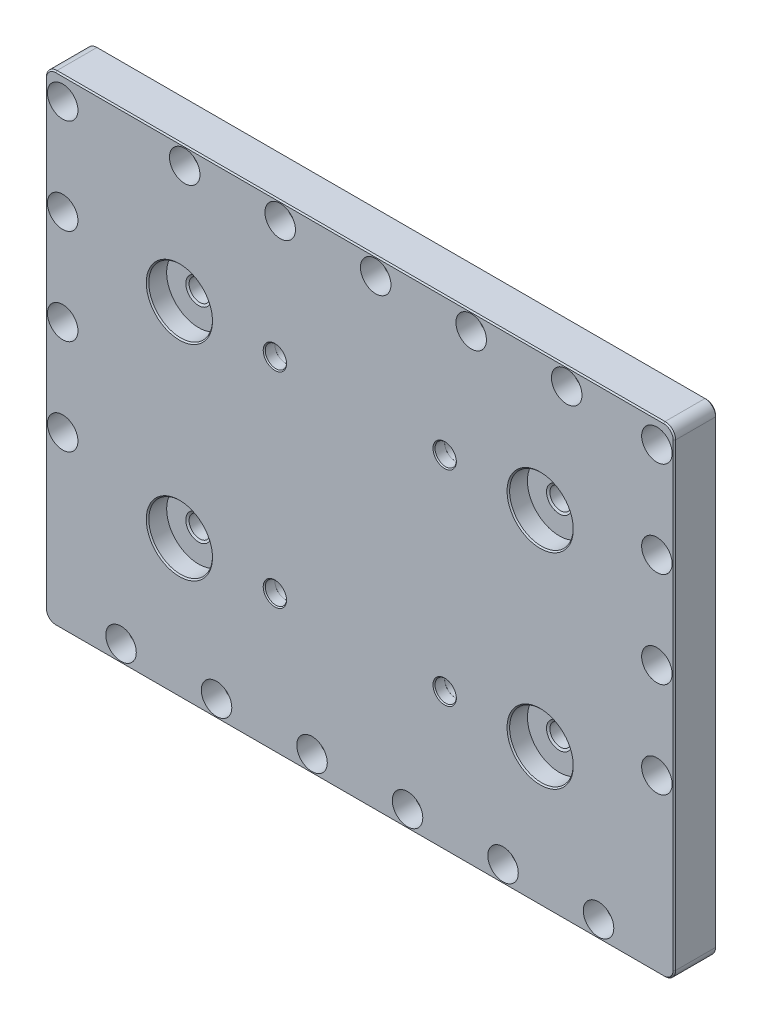
from build123d import *

# Parameters (mm, degrees)
SKETCH1_W                                     = 376.555
SKETCH1_H                                     = 287.655
EXTRUDE1_DEPTH                                = 25.4
CBORE_FOR_3_8_SOCKET_HEAD_CAP_SCREW3_AT_COUNT = 2
CBORE_FOR_3_8_SOCKET_HEAD_CAP_SCREW3_AT_PITCH = 57.15
CBORE_FOR_3_8_SOCKET_HEAD_CAP_SCREW3_2_COUNT  = 2
CBORE_FOR_3_8_SOCKET_HEAD_CAP_SCREW3_2_PITCH  = 114.3
CBORE_FOR_3_8_SOCKET_HEAD_CAP_SCREW3_3_COUNT  = 2
CBORE_FOR_3_8_SOCKET_HEAD_CAP_SCREW3_3_PITCH  = 171.45
CBORE_FOR_3_8_SOCKET_HEAD_CAP_SCREW3_4_COUNT  = 2
CBORE_FOR_3_8_SOCKET_HEAD_CAP_SCREW3_4_PITCH  = 228.6
CBORE_FOR_3_8_SOCKET_HEAD_CAP_SCREW3_5_COUNT  = 2
CBORE_FOR_3_8_SOCKET_HEAD_CAP_SCREW3_5_PITCH  = 269.407683632
CBORE_FOR_3_8_SOCKET_HEAD_CAP_SCREW3_6_COUNT  = 2
CBORE_FOR_3_8_SOCKET_HEAD_CAP_SCREW3_6_PITCH  = 283.198609636
CBORE_FOR_3_8_SOCKET_HEAD_CAP_SCREW3_7_COUNT  = 2
CBORE_FOR_3_8_SOCKET_HEAD_CAP_SCREW3_7_PITCH  = 307.17202021
CBORE_FOR_3_8_SOCKET_HEAD_CAP_SCREW3_8_COUNT  = 2
CBORE_FOR_3_8_SOCKET_HEAD_CAP_SCREW3_8_PITCH  = 339.175607171
CBORE_FOR_3_8_SOCKET_HEAD_CAP_SCREW3_9_COUNT  = 2
CBORE_FOR_3_8_SOCKET_HEAD_CAP_SCREW3_9_PITCH  = 377.170757085
CBORE_FOR_3_8_SOCKET_HEAD_CAP_SCREW3_10_COUNT = 2
CBORE_FOR_3_8_SOCKET_HEAD_CAP_SCREW3_10_PITCH = 285.75
CBORE_FOR_3_8_SOCKET_HEAD_CAP_SCREW4_AT_COUNT = 2
CBORE_FOR_3_8_SOCKET_HEAD_CAP_SCREW4_AT_PITCH = 57.15
CBORE_FOR_3_8_SOCKET_HEAD_CAP_SCREW4_2_COUNT  = 2
CBORE_FOR_3_8_SOCKET_HEAD_CAP_SCREW4_2_PITCH  = 114.3
CBORE_FOR_3_8_SOCKET_HEAD_CAP_SCREW4_3_COUNT  = 2
CBORE_FOR_3_8_SOCKET_HEAD_CAP_SCREW4_3_PITCH  = 171.45
CBORE_FOR_3_8_SOCKET_HEAD_CAP_SCREW4_4_COUNT  = 2
CBORE_FOR_3_8_SOCKET_HEAD_CAP_SCREW4_4_PITCH  = 355.6
CBORE_FOR_3_8_SOCKET_HEAD_CAP_SCREW4_5_COUNT  = 2
CBORE_FOR_3_8_SOCKET_HEAD_CAP_SCREW4_5_PITCH  = 360.163133177
CBORE_FOR_3_8_SOCKET_HEAD_CAP_SCREW4_6_COUNT  = 2
CBORE_FOR_3_8_SOCKET_HEAD_CAP_SCREW4_6_PITCH  = 373.518205714
CBORE_FOR_3_8_SOCKET_HEAD_CAP_SCREW4_7_COUNT  = 2
CBORE_FOR_3_8_SOCKET_HEAD_CAP_SCREW4_7_PITCH  = 394.773938476
FILLET3_R                                     = 6.35
CHAMFER3_SIZE                                 = 0.762
CBORE_FOR_1_2_SOCKET_HEAD_CAP_SCREW1_AT_COUNT = 2
CBORE_FOR_1_2_SOCKET_HEAD_CAP_SCREW1_AT_PITCH = 101.6
CBORE_FOR_1_2_SOCKET_HEAD_CAP_SCREW1_2_COUNT  = 2
CBORE_FOR_1_2_SOCKET_HEAD_CAP_SCREW1_2_PITCH  = 122.555
CBORE_FOR_1_2_SOCKET_HEAD_CAP_SCREW1_3_COUNT  = 2
CBORE_FOR_1_2_SOCKET_HEAD_CAP_SCREW1_3_PITCH  = 159.192612972
SKETCH29_R                                    = 19.05
EXTRUDE8_DEPTH                                = 11.43
F_1_2_13_TAPPED_HOLE1_AT_2_COUNT              = 2
F_1_2_13_TAPPED_HOLE1_AT_2_PITCH              = 215.9
F_1_2_13_TAPPED_HOLE1_AT_3_COUNT              = 2
F_1_2_13_TAPPED_HOLE1_AT_3_PITCH              = 248.259013985
F_1_2_13_TAPPED_HOLE1_AT_4_COUNT              = 2
F_1_2_13_TAPPED_HOLE1_AT_4_PITCH              = 122.555
CHAMFER5_SIZE                                 = 0.762


with BuildPart() as part:
    # Sketch1 → Extrude1 (new body)
    with BuildSketch(Plane.XY):
        with Locations((0, 143.8275)):
            Rectangle(SKETCH1_W, SKETCH1_H)
    extrude(amount=EXTRUDE1_DEPTH)

    # Sketch7 → CBORE for 3/8 Socket Head Cap Screw3 (revolve, cut)
    with BuildSketch(Plane(origin=(-142.875, 10.4775, 25.4), x_dir=(0, -1, 0), z_dir=(1, 0, 0))):
        Polygon((0, 0), (0, 25.4), (6.35, 25.4), (5.5626, 24.6126), (5.5626, 12.7), (9.1313, 12.7), (9.1313, 0), align=None)
    cbore_for_3_8_socket_head_cap_screw3 = revolve(axis=Axis((-142.875, 10.4775, 31.75), (0, 0, -1)), mode=Mode.SUBTRACT)

    # CBORE for 3/8 Socket Head Cap Screw3 at: CBORE for 3/8 Socket Head Cap Screw3 ×2
    with Locations(*[(i * CBORE_FOR_3_8_SOCKET_HEAD_CAP_SCREW3_AT_PITCH, 0, 0) for i in range(1, CBORE_FOR_3_8_SOCKET_HEAD_CAP_SCREW3_AT_COUNT)]):
        add(cbore_for_3_8_socket_head_cap_screw3, mode=Mode.SUBTRACT)

    # CBORE for 3_8 Socket Head Cap Screw3 2: CBORE for 3/8 Socket Head Cap Screw3 ×2
    with Locations(*[(i * CBORE_FOR_3_8_SOCKET_HEAD_CAP_SCREW3_2_PITCH, 0, 0) for i in range(1, CBORE_FOR_3_8_SOCKET_HEAD_CAP_SCREW3_2_COUNT)]):
        add(cbore_for_3_8_socket_head_cap_screw3, mode=Mode.SUBTRACT)

    # CBORE for 3_8 Socket Head Cap Screw3 3: CBORE for 3/8 Socket Head Cap Screw3 ×2
    with Locations(*[(i * CBORE_FOR_3_8_SOCKET_HEAD_CAP_SCREW3_3_PITCH, 0, 0) for i in range(1, CBORE_FOR_3_8_SOCKET_HEAD_CAP_SCREW3_3_COUNT)]):
        add(cbore_for_3_8_socket_head_cap_screw3, mode=Mode.SUBTRACT)

    # CBORE for 3_8 Socket Head Cap Screw3 4: CBORE for 3/8 Socket Head Cap Screw3 ×2
    with Locations(*[(i * CBORE_FOR_3_8_SOCKET_HEAD_CAP_SCREW3_4_PITCH, 0, 0) for i in range(1, CBORE_FOR_3_8_SOCKET_HEAD_CAP_SCREW3_4_COUNT)]):
        add(cbore_for_3_8_socket_head_cap_screw3, mode=Mode.SUBTRACT)

    # CBORE for 3_8 Socket Head Cap Screw3 5: CBORE for 3/8 Socket Head Cap Screw3 ×2
    with Locations(*[Vector(0.141421356, 0.989949494, 0) * (i * CBORE_FOR_3_8_SOCKET_HEAD_CAP_SCREW3_5_PITCH) for i in range(1, CBORE_FOR_3_8_SOCKET_HEAD_CAP_SCREW3_5_COUNT)]):
        add(cbore_for_3_8_socket_head_cap_screw3, mode=Mode.SUBTRACT)

    # CBORE for 3_8 Socket Head Cap Screw3 6: CBORE for 3/8 Socket Head Cap Screw3 ×2
    with Locations(*[Vector(0.336336397, 0.941741912, 0) * (i * CBORE_FOR_3_8_SOCKET_HEAD_CAP_SCREW3_6_PITCH) for i in range(1, CBORE_FOR_3_8_SOCKET_HEAD_CAP_SCREW3_6_COUNT)]):
        add(cbore_for_3_8_socket_head_cap_screw3, mode=Mode.SUBTRACT)

    # CBORE for 3_8 Socket Head Cap Screw3 7: CBORE for 3/8 Socket Head Cap Screw3 ×2
    with Locations(*[Vector(0.496138938, 0.868243142, 0) * (i * CBORE_FOR_3_8_SOCKET_HEAD_CAP_SCREW3_7_PITCH) for i in range(1, CBORE_FOR_3_8_SOCKET_HEAD_CAP_SCREW3_7_COUNT)]):
        add(cbore_for_3_8_socket_head_cap_screw3, mode=Mode.SUBTRACT)

    # CBORE for 3_8 Socket Head Cap Screw3 8: CBORE for 3/8 Socket Head Cap Screw3 ×2
    with Locations(*[Vector(0.617821552, 0.786318339, 0) * (i * CBORE_FOR_3_8_SOCKET_HEAD_CAP_SCREW3_8_PITCH) for i in range(1, CBORE_FOR_3_8_SOCKET_HEAD_CAP_SCREW3_8_COUNT)]):
        add(cbore_for_3_8_socket_head_cap_screw3, mode=Mode.SUBTRACT)

    # CBORE for 3_8 Socket Head Cap Screw3 9: CBORE for 3/8 Socket Head Cap Screw3 ×2
    with Locations(*[Vector(0.707106781, 0.707106781, 0) * (i * CBORE_FOR_3_8_SOCKET_HEAD_CAP_SCREW3_9_PITCH) for i in range(1, CBORE_FOR_3_8_SOCKET_HEAD_CAP_SCREW3_9_COUNT)]):
        add(cbore_for_3_8_socket_head_cap_screw3, mode=Mode.SUBTRACT)

    # CBORE for 3_8 Socket Head Cap Screw3 10: CBORE for 3/8 Socket Head Cap Screw3 ×2
    with Locations(*[(i * CBORE_FOR_3_8_SOCKET_HEAD_CAP_SCREW3_10_PITCH, 0, 0) for i in range(1, CBORE_FOR_3_8_SOCKET_HEAD_CAP_SCREW3_10_COUNT)]):
        add(cbore_for_3_8_socket_head_cap_screw3, mode=Mode.SUBTRACT)

    # Sketch18 → CBORE for 3/8 Socket Head Cap Screw4 (revolve, cut)
    with BuildSketch(Plane(origin=(-177.8, 274.0025, 25.4), x_dir=(0, -1, 0), z_dir=(1, 0, 0))):
        Polygon((0, 0), (0, 25.4), (6.35, 25.4), (5.5626, 24.6126), (5.5626, 14.224), (9.1313, 14.224), (9.1313, 0), align=None)
    cbore_for_3_8_socket_head_cap_screw4 = revolve(axis=Axis((-177.8, 274.0025, 31.75), (0, 0, -1)), mode=Mode.SUBTRACT)

    # CBORE for 3/8 Socket Head Cap Screw4 at: CBORE for 3/8 Socket Head Cap Screw4 ×2
    with Locations(*[(0, -i * CBORE_FOR_3_8_SOCKET_HEAD_CAP_SCREW4_AT_PITCH, 0) for i in range(1, CBORE_FOR_3_8_SOCKET_HEAD_CAP_SCREW4_AT_COUNT)]):
        add(cbore_for_3_8_socket_head_cap_screw4, mode=Mode.SUBTRACT)

    # CBORE for 3_8 Socket Head Cap Screw4 2: CBORE for 3/8 Socket Head Cap Screw4 ×2
    with Locations(*[(0, -i * CBORE_FOR_3_8_SOCKET_HEAD_CAP_SCREW4_2_PITCH, 0) for i in range(1, CBORE_FOR_3_8_SOCKET_HEAD_CAP_SCREW4_2_COUNT)]):
        add(cbore_for_3_8_socket_head_cap_screw4, mode=Mode.SUBTRACT)

    # CBORE for 3_8 Socket Head Cap Screw4 3: CBORE for 3/8 Socket Head Cap Screw4 ×2
    with Locations(*[(0, -i * CBORE_FOR_3_8_SOCKET_HEAD_CAP_SCREW4_3_PITCH, 0) for i in range(1, CBORE_FOR_3_8_SOCKET_HEAD_CAP_SCREW4_3_COUNT)]):
        add(cbore_for_3_8_socket_head_cap_screw4, mode=Mode.SUBTRACT)

    # CBORE for 3_8 Socket Head Cap Screw4 4: CBORE for 3/8 Socket Head Cap Screw4 ×2
    with Locations(*[(i * CBORE_FOR_3_8_SOCKET_HEAD_CAP_SCREW4_4_PITCH, 0, 0) for i in range(1, CBORE_FOR_3_8_SOCKET_HEAD_CAP_SCREW4_4_COUNT)]):
        add(cbore_for_3_8_socket_head_cap_screw4, mode=Mode.SUBTRACT)

    # CBORE for 3_8 Socket Head Cap Screw4 5: CBORE for 3/8 Socket Head Cap Screw4 ×2
    with Locations(*[Vector(0.987330371, -0.158678095, 0) * (i * CBORE_FOR_3_8_SOCKET_HEAD_CAP_SCREW4_5_PITCH) for i in range(1, CBORE_FOR_3_8_SOCKET_HEAD_CAP_SCREW4_5_COUNT)]):
        add(cbore_for_3_8_socket_head_cap_screw4, mode=Mode.SUBTRACT)

    # CBORE for 3_8 Socket Head Cap Screw4 6: CBORE for 3/8 Socket Head Cap Screw4 ×2
    with Locations(*[Vector(0.952028561, -0.30600918, 0) * (i * CBORE_FOR_3_8_SOCKET_HEAD_CAP_SCREW4_6_PITCH) for i in range(1, CBORE_FOR_3_8_SOCKET_HEAD_CAP_SCREW4_6_COUNT)]):
        add(cbore_for_3_8_socket_head_cap_screw4, mode=Mode.SUBTRACT)

    # CBORE for 3_8 Socket Head Cap Screw4 7: CBORE for 3/8 Socket Head Cap Screw4 ×2
    with Locations(*[Vector(0.900768681, -0.434299186, 0) * (i * CBORE_FOR_3_8_SOCKET_HEAD_CAP_SCREW4_7_PITCH) for i in range(1, CBORE_FOR_3_8_SOCKET_HEAD_CAP_SCREW4_7_COUNT)]):
        add(cbore_for_3_8_socket_head_cap_screw4, mode=Mode.SUBTRACT)

    # Fillet3
    fillet3_edges = [part.edges().sort_by_distance(p)[0] for p in [
        (-188.2775, 287.655, 12.7),
        (188.2775, 287.655, 12.7),
        (188.2775, 0, 12.7),
        (-188.2775, 0, 12.7),
    ]]
    fillet(fillet3_edges, radius=FILLET3_R)

    # Chamfer3
    chamfer3_edges = [part.edges().sort_by_distance(p)[0] for p in [
        (0, 287.655, 0),
        (0, 287.655, 25.4),
        (-188.2775, 143.8275, 0),
        (188.2775, 143.8275, 0),
        (0, 0, 0),
        (-186.417628061, 285.795128061, 0),
        (-186.417628061, 1.859871939, 0),
        (186.417628061, 1.859871939, 0),
        (186.417628061, 285.795128061, 0),
        (188.2775, 143.8275, 25.4),
        (-188.2775, 143.8275, 25.4),
        (0, 0, 25.4),
        (-186.417628061, 285.795128061, 25.4),
        (-186.417628061, 1.859871939, 25.4),
        (186.417628061, 1.859871939, 25.4),
        (186.417628061, 285.795128061, 25.4),
    ]]
    chamfer(chamfer3_edges, length=CHAMFER3_SIZE)

    # Sketch23 → CBORE for 1/2 Socket Head Cap Screw1 (revolve, cut)
    with BuildSketch(Plane(origin=(-50.8, 205.105, 25.4), x_dir=(0, -1, 0), z_dir=(1, 0, 0))):
        Polygon((0, 0), (0, 25.4), (6.985, 25.4), (6.35, 24.765), (6.35, 6.35), (6.3754, 6.35), (6.3754, 0.6096), (6.985, 0), align=None)
    cbore_for_1_2_socket_head_cap_screw1 = revolve(axis=Axis((-50.8, 205.105, 31.75), (0, 0, -1)), mode=Mode.SUBTRACT)

    # CBORE for 1/2 Socket Head Cap Screw1 at: CBORE for 1/2 Socket Head Cap Screw1 ×2
    with Locations(*[(i * CBORE_FOR_1_2_SOCKET_HEAD_CAP_SCREW1_AT_PITCH, 0, 0) for i in range(1, CBORE_FOR_1_2_SOCKET_HEAD_CAP_SCREW1_AT_COUNT)]):
        add(cbore_for_1_2_socket_head_cap_screw1, mode=Mode.SUBTRACT)

    # CBORE for 1_2 Socket Head Cap Screw1 2: CBORE for 1/2 Socket Head Cap Screw1 ×2
    with Locations(*[(0, -i * CBORE_FOR_1_2_SOCKET_HEAD_CAP_SCREW1_2_PITCH, 0) for i in range(1, CBORE_FOR_1_2_SOCKET_HEAD_CAP_SCREW1_2_COUNT)]):
        add(cbore_for_1_2_socket_head_cap_screw1, mode=Mode.SUBTRACT)

    # CBORE for 1_2 Socket Head Cap Screw1 3: CBORE for 1/2 Socket Head Cap Screw1 ×2
    with Locations(*[Vector(0.638220569, -0.769853561, 0) * (i * CBORE_FOR_1_2_SOCKET_HEAD_CAP_SCREW1_3_PITCH) for i in range(1, CBORE_FOR_1_2_SOCKET_HEAD_CAP_SCREW1_3_COUNT)]):
        add(cbore_for_1_2_socket_head_cap_screw1, mode=Mode.SUBTRACT)

    # Sketch29 → Extrude8 (cut)
    with BuildSketch(Plane.XY.offset(25.4)):
        with Locations((-107.95, 205.105)):
            Circle(SKETCH29_R)
        with Locations(Location((-107.95, 82.55, 0), (0, 0, 180))):  # turned: the seam where the file's is
            Circle(SKETCH29_R)
        with Locations((107.95, 82.55)):
            Circle(SKETCH29_R)
        with Locations(Location((107.95, 205.105, 0), (0, 0, 180))):  # turned: the seam where the file's is
            Circle(SKETCH29_R)
    extrude(amount=-EXTRUDE8_DEPTH, mode=Mode.SUBTRACT)

    # Sketch30 → 1/2-13 Tapped Hole1 (revolve, cut)
    with BuildSketch(Plane(origin=(-107.95, 205.105, 13.97), x_dir=(0, -1, 0), z_dir=(1, 0, 0))):
        Polygon((0, 0), (0, 13.97), (8.89, 13.97), (6.35, 12.503530316), (6.35, 0.733234842), (7.62, 0), align=None)
    f_1_2_13_tapped_hole1 = revolve(axis=Axis((-107.95, 205.105, 20.32), (0, 0, -1)), mode=Mode.SUBTRACT)

    # 1/2-13 Tapped Hole1 at 2: 1/2-13 Tapped Hole1 ×2
    with Locations(*[(i * F_1_2_13_TAPPED_HOLE1_AT_2_PITCH, 0, 0) for i in range(1, F_1_2_13_TAPPED_HOLE1_AT_2_COUNT)]):
        add(f_1_2_13_tapped_hole1, mode=Mode.SUBTRACT)

    # 1/2-13 Tapped Hole1 at 3: 1/2-13 Tapped Hole1 ×2
    with Locations(*[Vector(0.869656237, -0.493657805, 0) * (i * F_1_2_13_TAPPED_HOLE1_AT_3_PITCH) for i in range(1, F_1_2_13_TAPPED_HOLE1_AT_3_COUNT)]):
        add(f_1_2_13_tapped_hole1, mode=Mode.SUBTRACT)

    # 1/2-13 Tapped Hole1 at 4: 1/2-13 Tapped Hole1 ×2
    with Locations(*[(0, -i * F_1_2_13_TAPPED_HOLE1_AT_4_PITCH, 0) for i in range(1, F_1_2_13_TAPPED_HOLE1_AT_4_COUNT)]):
        add(f_1_2_13_tapped_hole1, mode=Mode.SUBTRACT)

    # Chamfer5
    chamfer5_edges = [part.edges().sort_by_distance(p)[0] for p in [
        (-127, 205.105, 25.4),
        (-88.9, 82.55, 25.4),
        (88.9, 82.55, 25.4),
        (127, 205.105, 25.4),
    ]]
    chamfer(chamfer5_edges, length=CHAMFER5_SIZE)


solid = part.part
